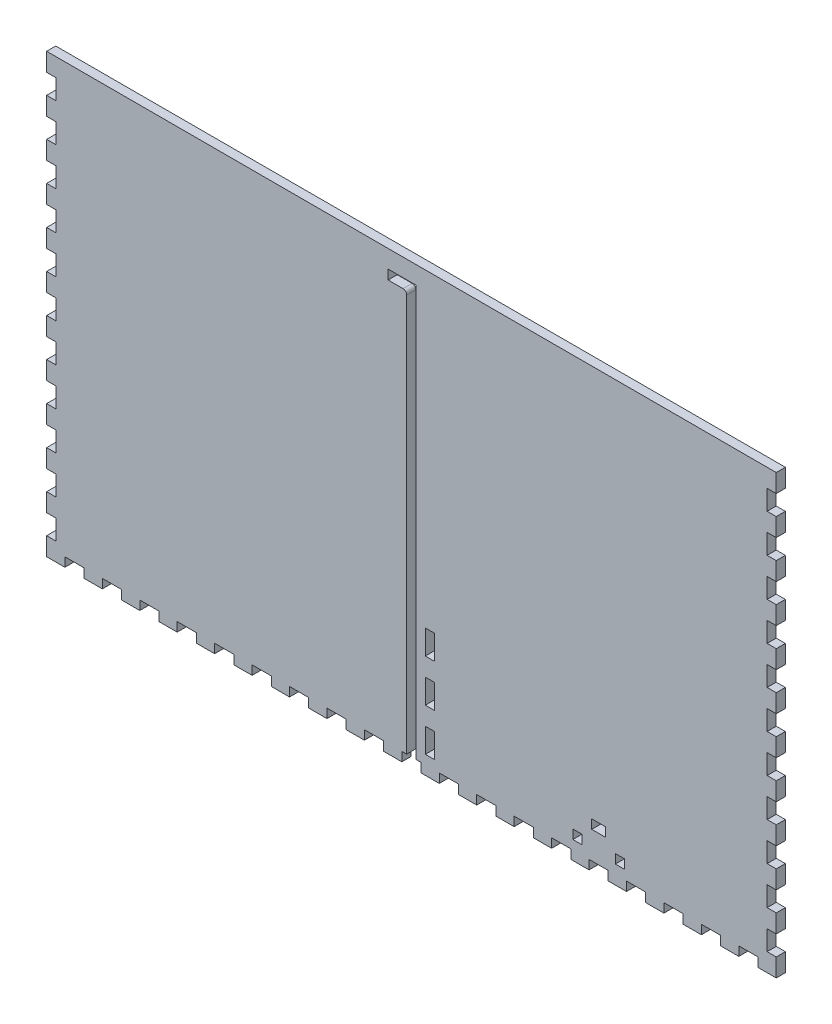
from build123d import *

# Parameters (mm, degrees)
SKETCH1_W           = 508
SKETCH1_H           = 190.5
BOSS_EXTRUDE1_DEPTH = 6.35
SKETCH2_W           = 508
SKETCH2_H           = 190.5
SKETCH2_W_2         = 495.3
SKETCH2_H_2         = 177.8
BOSS_EXTRUDE2_DEPTH = 298.45
SKETCH3_W           = 6.35
SKETCH3_H           = 16.933333333
SKETCH3_H_2         = 16.933333334
CUT_EXTRUDE1_DEPTH  = 12.7
SKETCH4_W           = 6.35
SKETCH4_H           = 15.875
CUT_EXTRUDE2_DEPTH  = 6.35
SKETCH6_W           = 551.127140902
SKETCH6_H           = 227.623239157
CUT_EXTRUDE5_DEPTH  = 305.8
SKETCH5_W           = 13.368421053
SKETCH5_H           = 6.35
SKETCH5_W_2         = 13.368421052
CUT_EXTRUDE6_DEPTH  = 6.35
SKETCH7_W           = 6.35
SKETCH7_H           = 13.854545455
SKETCH7_H_2         = 13.854545454
CUT_EXTRUDE7_DEPTH  = 6.35
SKETCH8_W           = 9.652
SKETCH8_H           = 6.35
SKETCH8_W_2         = 6.35
LEVER_HOLE_DEPTH    = 7.35


with BuildPart() as part:
    # Sketch1 → Boss-Extrude1 (new body)
    with BuildSketch(Plane(origin=(0, 0, 0), x_dir=(1, 0, 0), z_dir=(0, 1, 0))):
        Rectangle(SKETCH1_W, SKETCH1_H)
    extrude(amount=BOSS_EXTRUDE1_DEPTH)

    # Sketch2 → Boss-Extrude2 (add)
    with BuildSketch(Plane(origin=(0, 6.35, 0), x_dir=(1, 0, 0), z_dir=(0, 1, 0))):
        Rectangle(SKETCH2_W, SKETCH2_H)
        Rectangle(SKETCH2_W_2, SKETCH2_H_2, mode=Mode.SUBTRACT)
    extrude(amount=BOSS_EXTRUDE2_DEPTH)

    # Sketch3 → Cut-Extrude1 (cut)
    with BuildSketch(Plane.XY.offset(95.25)):
        with BuildLine():
            Line((-3.302, 283.21), (-3.302, 6.35))
            Line((-3.302, 6.35), (3.302, 6.35))
            Line((3.302, 6.35), (3.302, 292.354))
            Line((3.302, 292.354), (-16.256, 292.354))
            Line((-16.256, 292.354), (-16.256, 285.75))
            Line((-16.256, 285.75), (-5.842, 285.75))
            ThreePointArc((-5.842, 285.75), (-4.045948776, 285.006051224), (-3.302, 283.21))
        make_face()
        with Locations((12.827, 80.433333334)):
            Rectangle(SKETCH3_W, SKETCH3_H)
        with Locations((12.827, 50.8)):
            Rectangle(SKETCH3_W, SKETCH3_H_2)
        with Locations((12.827, 21.166666667)):
            Rectangle(SKETCH3_W, SKETCH3_H)
    extrude(amount=-CUT_EXTRUDE1_DEPTH, mode=Mode.SUBTRACT)

    # Sketch4 → Cut-Extrude2 (cut)
    with BuildSketch(Plane.XY.offset(-88.9)):
        with Locations((-19.431, 284.1625)):
            Rectangle(SKETCH4_W, SKETCH4_H)
        with Locations((-19.431, 255.5875)):
            Rectangle(SKETCH4_W, SKETCH4_H)
        with Locations((-19.431, 227.0125)):
            Rectangle(SKETCH4_W, SKETCH4_H)
        with Locations((-19.431, 198.4375)):
            Rectangle(SKETCH4_W, SKETCH4_H)
        with Locations((-19.431, 169.8625)):
            Rectangle(SKETCH4_W, SKETCH4_H)
        with Locations((-19.431, 141.2875)):
            Rectangle(SKETCH4_W, SKETCH4_H)
        with Locations((-19.431, 112.7125)):
            Rectangle(SKETCH4_W, SKETCH4_H)
        with Locations((-19.431, 84.1375)):
            Rectangle(SKETCH4_W, SKETCH4_H)
        with Locations((-19.431, 55.5625)):
            Rectangle(SKETCH4_W, SKETCH4_H)
        with Locations((-19.431, 26.9875)):
            Rectangle(SKETCH4_W, SKETCH4_H)
    cut_extrude2 = extrude(amount=-CUT_EXTRUDE2_DEPTH, mode=Mode.SUBTRACT)

    # Mirror1: Cut-Extrude2 across plane
    add(cut_extrude2.mirror(Plane.ZY.offset(6.477)), mode=Mode.SUBTRACT)

    # Sketch6 → Cut-Extrude5 (cut, through all)
    with BuildSketch(Plane(origin=(0, 0, 0), x_dir=(1, 0, 0), z_dir=(0, 1, 0))):
        with Locations((15.161260543, 24.911619578)):
            Rectangle(SKETCH6_W, SKETCH6_H)
    extrude(amount=CUT_EXTRUDE5_DEPTH, mode=Mode.SUBTRACT)

    # Sketch5 → Cut-Extrude6 (cut)
    with BuildSketch(Plane(origin=(0, 0, 0), x_dir=(-1, 0, 0), z_dir=(0, -1, 0))):
        with Locations((-234.615789474, -92.075)):
            Rectangle(SKETCH5_W, SKETCH5_H)
        with Locations((-208.547368421, -92.075)):
            Rectangle(SKETCH5_W_2, SKETCH5_H)
        with Locations((-182.478947369, -92.075)):
            Rectangle(SKETCH5_W, SKETCH5_H)
        with Locations((-156.410526316, -92.075)):
            Rectangle(SKETCH5_W, SKETCH5_H)
        with Locations((-130.342105263, -92.075)):
            Rectangle(SKETCH5_W_2, SKETCH5_H)
        with Locations((-104.273684211, -92.075)):
            Rectangle(SKETCH5_W, SKETCH5_H)
        with Locations((-78.205263158, -92.075)):
            Rectangle(SKETCH5_W_2, SKETCH5_H)
        with Locations((-52.136842106, -92.075)):
            Rectangle(SKETCH5_W, SKETCH5_H)
        with Locations((-26.068421052, -92.075)):
            Rectangle(SKETCH5_W, SKETCH5_H)
        with Locations((0, -92.075)):
            Rectangle(SKETCH5_W_2, SKETCH5_H)
        with Locations((26.068421052, -92.075)):
            Rectangle(SKETCH5_W, SKETCH5_H)
        with Locations((52.136842106, -92.075)):
            Rectangle(SKETCH5_W, SKETCH5_H)
        with Locations((78.205263158, -92.075)):
            Rectangle(SKETCH5_W_2, SKETCH5_H)
        with Locations((104.273684211, -92.075)):
            Rectangle(SKETCH5_W, SKETCH5_H)
        with Locations((130.342105263, -92.075)):
            Rectangle(SKETCH5_W_2, SKETCH5_H)
        with Locations((156.410526316, -92.075)):
            Rectangle(SKETCH5_W, SKETCH5_H)
        with Locations((182.478947369, -92.075)):
            Rectangle(SKETCH5_W, SKETCH5_H)
        with Locations((208.547368421, -92.075)):
            Rectangle(SKETCH5_W_2, SKETCH5_H)
        with Locations((234.615789474, -92.075)):
            Rectangle(SKETCH5_W, SKETCH5_H)
    extrude(amount=-CUT_EXTRUDE6_DEPTH, mode=Mode.SUBTRACT)

    # Sketch7 → Cut-Extrude7 (cut)
    with BuildSketch(Plane(origin=(254, 0, 0), x_dir=(0, 0, -1), z_dir=(1, 0, 0))):
        with Locations((-92.075, 285.172727273)):
            Rectangle(SKETCH7_W, SKETCH7_H)
        with Locations((-92.075, 258.618181818)):
            Rectangle(SKETCH7_W, SKETCH7_H_2)
        with Locations((-92.075, 232.063636364)):
            Rectangle(SKETCH7_W, SKETCH7_H)
        with Locations((-92.075, 205.509090909)):
            Rectangle(SKETCH7_W, SKETCH7_H_2)
        with Locations((-92.075, 178.954545455)):
            Rectangle(SKETCH7_W, SKETCH7_H)
        with Locations((-92.075, 152.4)):
            Rectangle(SKETCH7_W, SKETCH7_H_2)
        with Locations((-92.075, 125.845454546)):
            Rectangle(SKETCH7_W, SKETCH7_H)
        with Locations((-92.075, 99.290909091)):
            Rectangle(SKETCH7_W, SKETCH7_H_2)
        with Locations((-92.075, 72.736363637)):
            Rectangle(SKETCH7_W, SKETCH7_H)
        with Locations((-92.075, 46.181818182)):
            Rectangle(SKETCH7_W, SKETCH7_H_2)
        with Locations((-92.075, 19.627272728)):
            Rectangle(SKETCH7_W, SKETCH7_H)
    cut_extrude7 = extrude(amount=-CUT_EXTRUDE7_DEPTH, mode=Mode.SUBTRACT)

    # Mirror2: Cut-Extrude7 across plane
    add(cut_extrude7.mirror(Plane(origin=(0, 0, 0), x_dir=(0, 0, 1), z_dir=(1, 0, 0))), mode=Mode.SUBTRACT)

    # Sketch8 → Lever Hole (cut, through all)
    with BuildSketch(Plane.XY.offset(95.25)):
        with Locations((130.342105263, 28.575)):
            Rectangle(SKETCH8_W, SKETCH8_H)
        with Locations((115.546605263, 15.875)):
            Rectangle(SKETCH8_W_2, SKETCH8_H)
        with Locations((145.137605263, 15.875)):
            Rectangle(SKETCH8_W_2, SKETCH8_H)
    extrude(amount=-LEVER_HOLE_DEPTH, mode=Mode.SUBTRACT)


solid = part.part
